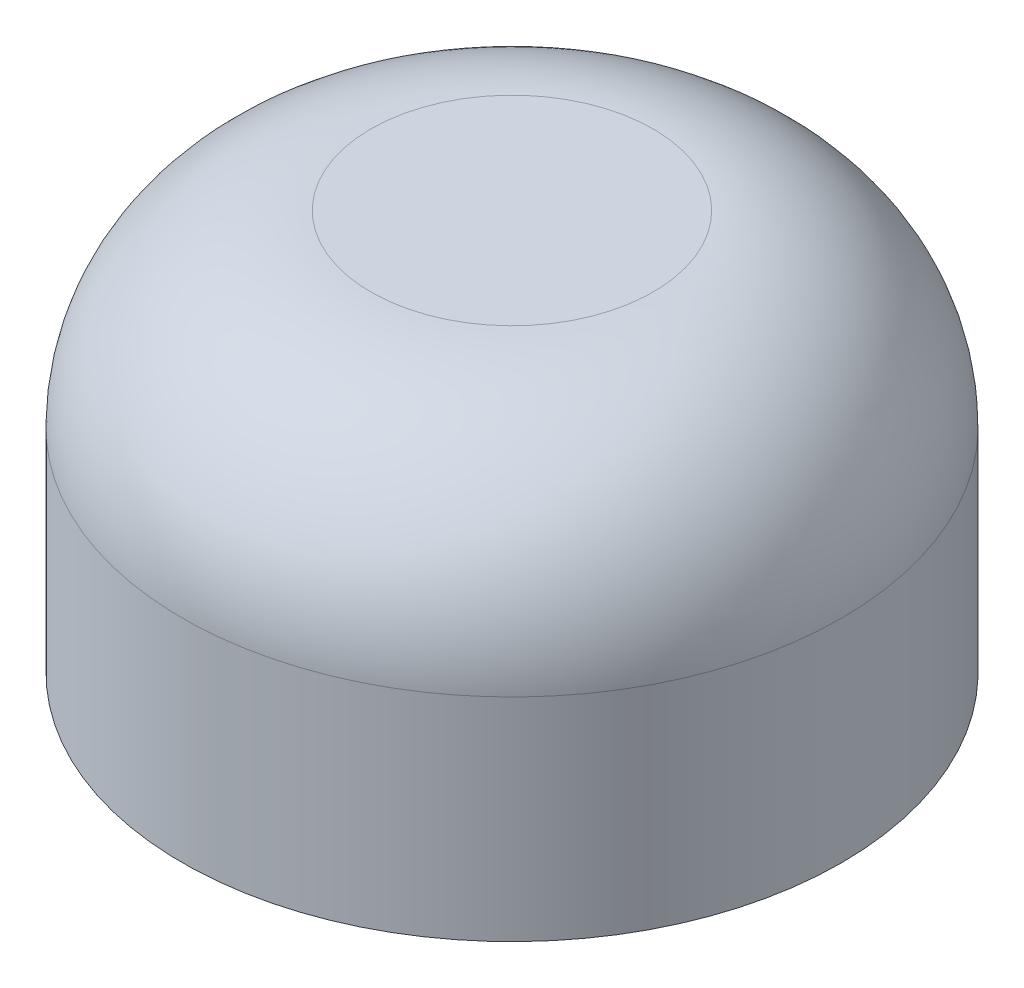
from build123d import *


with BuildPart() as part:
    # Schizzo1 → Rivoluzione1 (revolve)
    with BuildSketch(Plane.XY):
        with BuildLine():
            Line((0, 0), (1.5, 0))
            Line((1.5, 0), (1.5, -2.5))
            Line((1.5, -2.5), (3.5, -2.5))
            Line((3.5, -2.5), (3.5, -0.25))
            ThreePointArc((3.5, -0.25), (2.914213562, 1.164213562), (1.5, 1.75))
            Line((1.5, 1.75), (0, 1.75))
            Line((0, 1.75), (0, 0))
        make_face()
    revolve(axis=Axis((0, 1.75, 0), (0, -1, 0)))


solid = part.part
